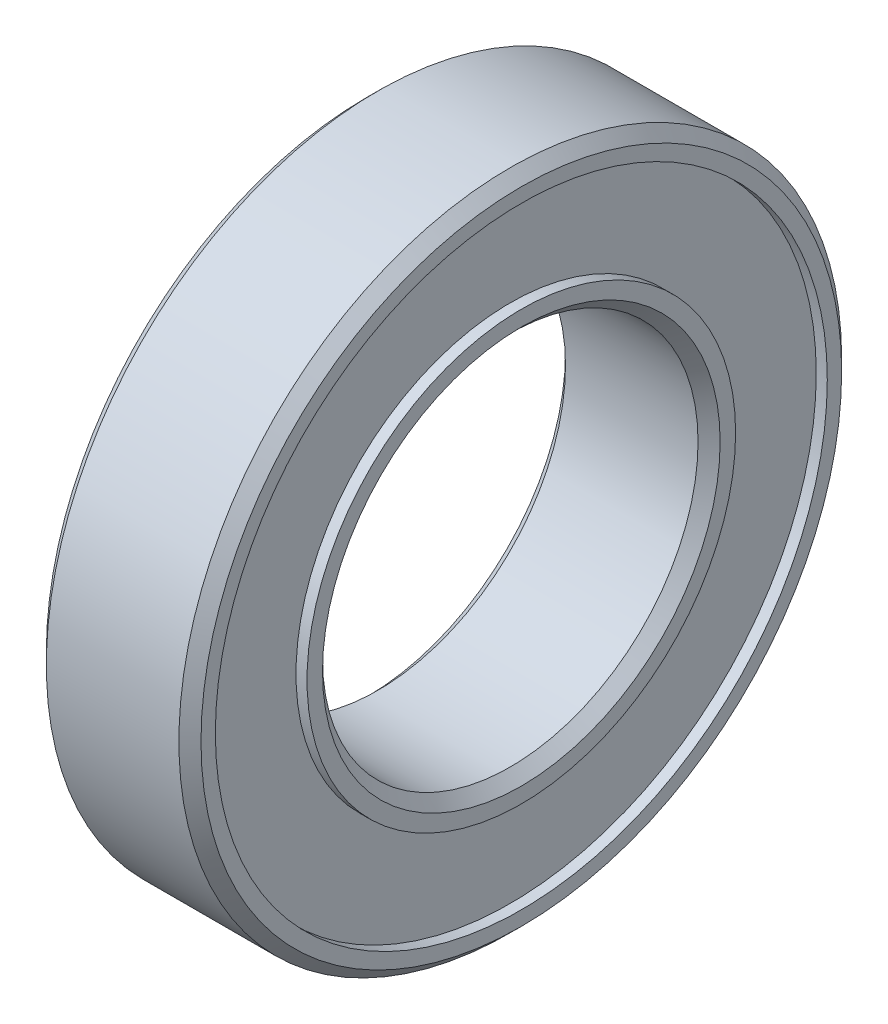
from build123d import *

# Parameters (mm, degrees)
SKETCH1_R           = 15
SKETCH1_R_2         = 8.5
BOSS_EXTRUDE1_DEPTH = 7
CHAMFER1_SIZE       = 0.5
SKETCH2_R           = 13.85
SKETCH2_R_2         = 9.7
CUT_EXTRUDE1_DEPTH  = 0.5
SKETCH3_R           = 13.85
SKETCH3_R_2         = 9.7
CUT_EXTRUDE2_DEPTH  = 0.5


with BuildPart() as part:
    # Sketch1 → Boss-Extrude1 (new body)
    with BuildSketch(Plane(origin=(0, 0, 0), x_dir=(0, 0, -1), z_dir=(1, 0, 0))):
        Circle(SKETCH1_R)
        Circle(SKETCH1_R_2, mode=Mode.SUBTRACT)
    extrude(amount=BOSS_EXTRUDE1_DEPTH)

    # Chamfer1
    chamfer1_edges = [part.edges().sort_by_distance(p)[0] for p in [
        (0, 0, 15),
        (7, 0, 15),
        (0, 0, 8.5),
        (7, 0, 8.5),
    ]]
    chamfer(chamfer1_edges, length=CHAMFER1_SIZE)

    # Sketch2 → Cut-Extrude1 (cut)
    with BuildSketch(Plane(origin=(7, 0, 0), x_dir=(0, 0, -1), z_dir=(1, 0, 0))):
        Circle(SKETCH2_R)
        Circle(SKETCH2_R_2, mode=Mode.SUBTRACT)
    extrude(amount=-CUT_EXTRUDE1_DEPTH, mode=Mode.SUBTRACT)

    # Sketch3 → Cut-Extrude2 (cut)
    with BuildSketch(Plane.ZY):
        Circle(SKETCH3_R)
        Circle(SKETCH3_R_2, mode=Mode.SUBTRACT)
    extrude(amount=-CUT_EXTRUDE2_DEPTH, mode=Mode.SUBTRACT)


solid = part.part
